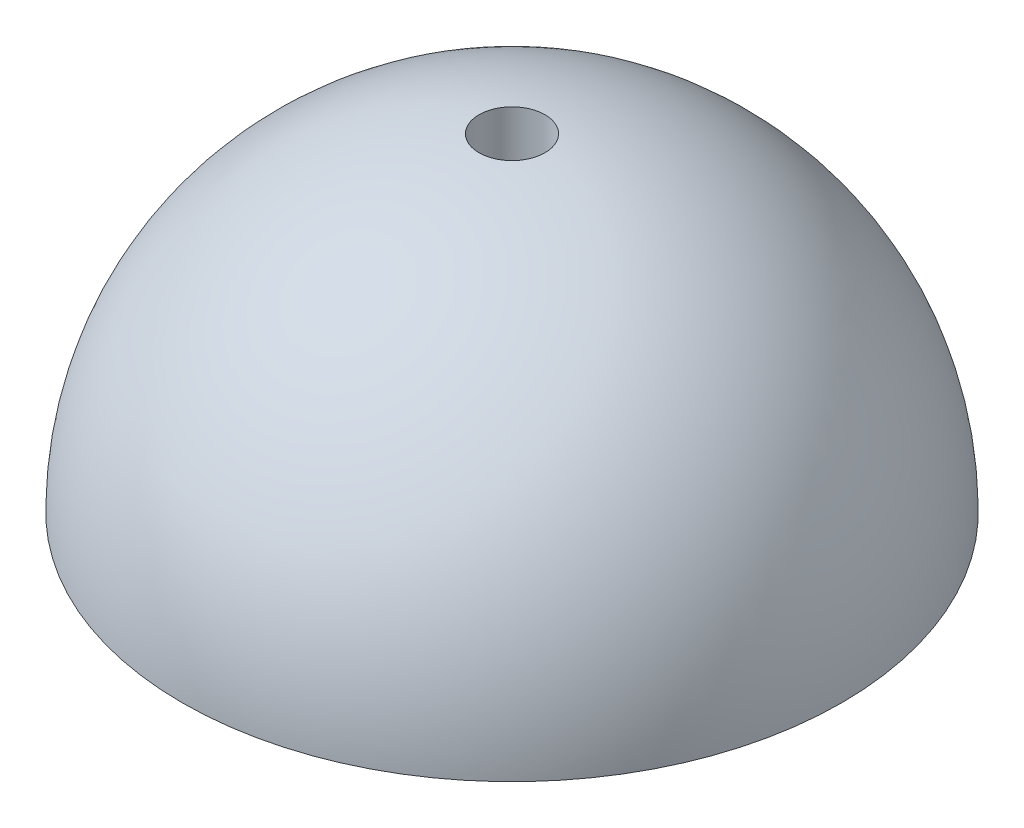
from build123d import *

# Parameters (mm, degrees)
CUT_EXTRUDE_1_REACH = 12
SKETCH_3_R          = 1


with BuildPart() as part:
    # 草图2 → 旋转1 (revolve)
    with BuildSketch(Plane.XY):
        with BuildLine():
            Line((0, 0), (10, 0))
            ThreePointArc((10, 0), (7.071067812, 7.071067812), (0, 10))
            Line((0, 10), (0, 0))
        make_face()
    revolve(axis=Axis((0, 10, 0), (0, -1, 0)))

    # 草图3 → 切除-拉伸1 (cut, up to next)
    with BuildSketch(Plane.XZ, mode=Mode.PRIVATE) as cut_extrude_1_sk1:
        Circle(SKETCH_3_R)
    cut_extrude_1_tool1 = extrude(cut_extrude_1_sk1.sketch, amount=-CUT_EXTRUDE_1_REACH, mode=Mode.PRIVATE) & part.part
    add(cut_extrude_1_tool1.solids().sort_by_distance((0, 0, 0))[0], mode=Mode.SUBTRACT)


solid = part.part
